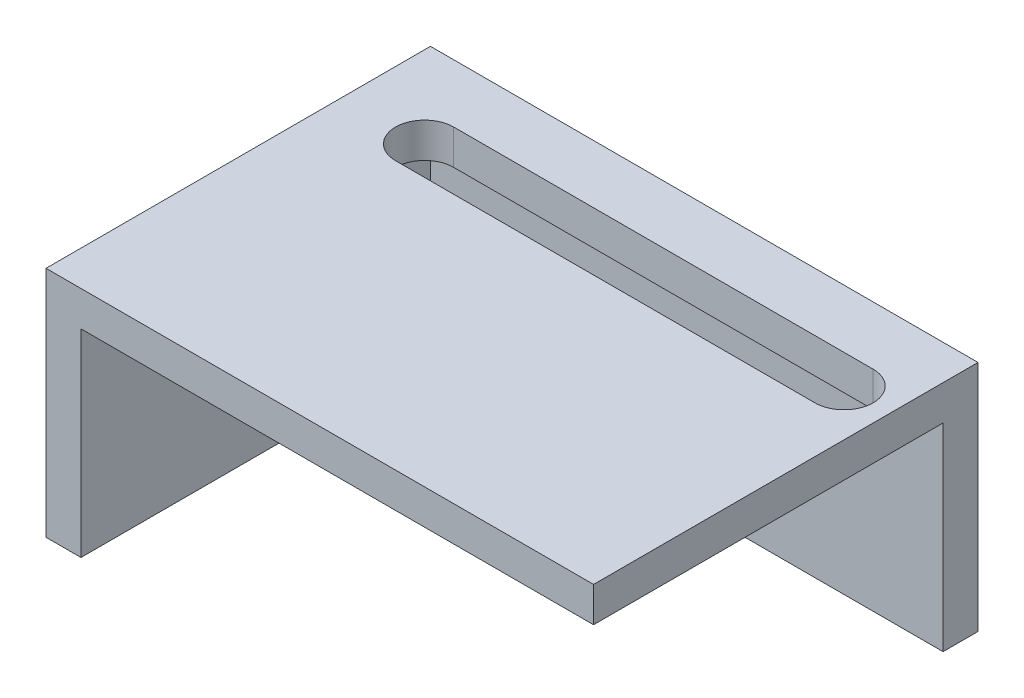
from build123d import *

# Parameters (mm, degrees)
SKETCH2_W           = 44
SKETCH2_H           = 30
BOSS_EXTRUDE1_DEPTH = 3
SKETCH3_W           = 44
SKETCH3_H           = 20
BOSS_EXTRUDE2_DEPTH = 3
SKETCH4_W           = 33
SKETCH4_H           = 20
BOSS_EXTRUDE3_DEPTH = 3
CUT_EXTRUDE1_DEPTH  = 3


with BuildPart() as part:
    # Sketch2 → Boss-Extrude1 (new body)
    with BuildSketch(Plane(origin=(0, 0, 0), x_dir=(1, 0, 0), z_dir=(0, 1, 0))):
        Rectangle(SKETCH2_W, SKETCH2_H)
    extrude(amount=BOSS_EXTRUDE1_DEPTH)

    # Sketch3 → Boss-Extrude2 (add)
    with BuildSketch(Plane(origin=(0, 0, -15), x_dir=(-1, 0, 0), z_dir=(0, 0, -1))):
        with Locations((0, -7)):
            Rectangle(SKETCH3_W, SKETCH3_H)
    extrude(amount=BOSS_EXTRUDE2_DEPTH)

    # Sketch4 → Boss-Extrude3 (add)
    with BuildSketch(Plane.ZY.offset(22)):
        with Locations((-1.5, -7)):
            Rectangle(SKETCH4_W, SKETCH4_H)
    extrude(amount=BOSS_EXTRUDE3_DEPTH)

    # Sketch5 → Cut-Extrude1 (cut)
    with BuildSketch(Plane.XZ):
        with BuildLine():
            Line((-18, -8), (18, -8))
            ThreePointArc((18, -8), (20.5, -10.5), (18, -13))
            Line((18, -13), (-18, -13))
            ThreePointArc((-18, -13), (-20.5, -10.5), (-18, -8))
        make_face()
    extrude(amount=-CUT_EXTRUDE1_DEPTH, mode=Mode.SUBTRACT)


solid = part.part
